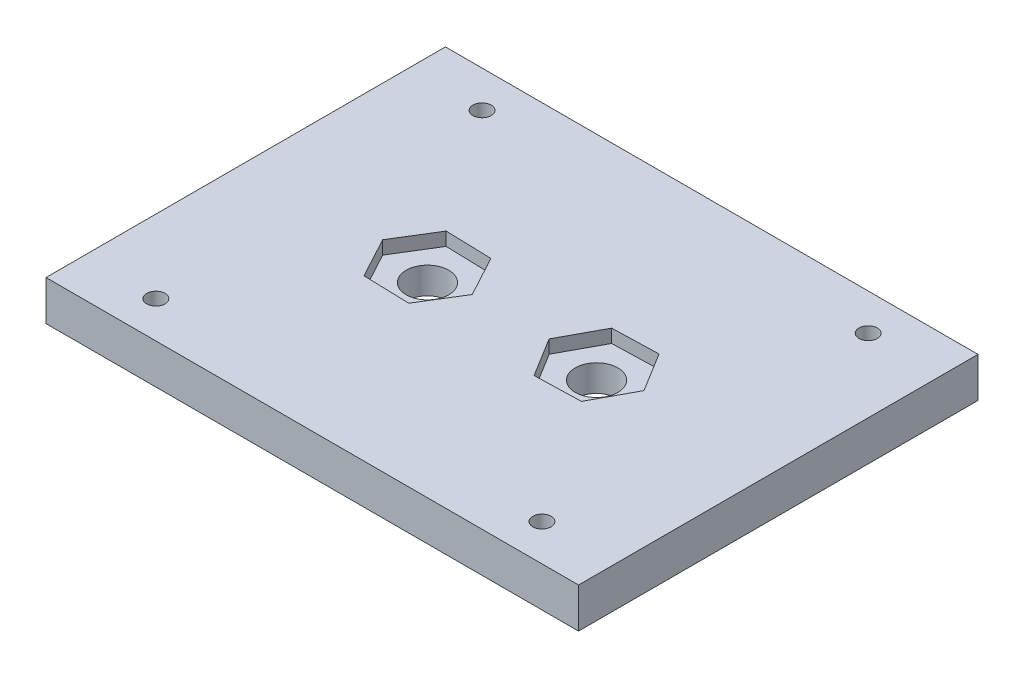
from build123d import *

# Parameters (mm, degrees)
SKETCH2_W               = 80
SKETCH2_H               = 60
BOSS_EXTRUDE2_DEPTH     = 6
SKETCH3_R               = 3.2
CUT_EXTRUDE1_DEPTH      = 6
CUT_EXTRUDE2_DEPTH      = 2
SKETCH6_R               = 1.375
CUT_EXTRUDE3_DEPTH      = 6
MIRROR4_COPY_1_SKETCH_R = 1.375
MIRROR4_COPY_1_DEPTH    = 6


with BuildPart() as part:
    # Sketch2 → Boss-Extrude2 (new body)
    with BuildSketch(Plane(origin=(0, 0, 0), x_dir=(1, 0, 0), z_dir=(0, 1, 0))):
        Rectangle(SKETCH2_W, SKETCH2_H)
    extrude(amount=BOSS_EXTRUDE2_DEPTH)

    # Sketch3 → Cut-Extrude1 (cut)
    with BuildSketch(Plane(origin=(0, 6, 0), x_dir=(1, 0, 0), z_dir=(0, 1, 0))):
        with Locations((-12.7, 0)):
            Circle(SKETCH3_R)
    cut_extrude1 = extrude(amount=-CUT_EXTRUDE1_DEPTH, mode=Mode.SUBTRACT)

    # Sketch5 → Cut-Extrude2 (cut)
    with BuildSketch(Plane(origin=(0, 6, 0), x_dir=(1, 0, 0), z_dir=(0, 1, 0))):
        Polygon((-9.409372911, -6.096865864), (-5.774645734, -0.198666278), (-9.065272823, 5.898199586), (-15.990627089, 6.096865864), (-19.625354266, 0.198666278), (-16.334727177, -5.898199586), align=None)
    cut_extrude2 = extrude(amount=-CUT_EXTRUDE2_DEPTH, mode=Mode.SUBTRACT)

    # Mirror2: Cut-Extrude1, Cut-Extrude2 across plane
    add(cut_extrude1.mirror(Plane(origin=(0, 0, 0), x_dir=(0, 0, 1), z_dir=(1, 0, 0))), mode=Mode.SUBTRACT)
    add(cut_extrude2.mirror(Plane(origin=(0, 0, 0), x_dir=(0, 0, 1), z_dir=(1, 0, 0))), mode=Mode.SUBTRACT)

    # Sketch6 → Cut-Extrude3 (cut)
    with BuildSketch(Plane(origin=(0, 6, 0), x_dir=(1, 0, 0), z_dir=(0, 1, 0))):
        with Locations((-29, 24.5)):
            Circle(SKETCH6_R)
    cut_extrude3 = extrude(amount=-CUT_EXTRUDE3_DEPTH, mode=Mode.SUBTRACT)

    # Mirror3: Cut-Extrude3 across plane
    add(cut_extrude3.mirror(Plane.XY), mode=Mode.SUBTRACT)

    # Mirror4: Cut-Extrude3 across plane
    add(cut_extrude3.mirror(Plane(origin=(0, 0, 0), x_dir=(0, 0, 1), z_dir=(1, 0, 0))), mode=Mode.SUBTRACT)

    # Mirror4 copy 1 sketch → Mirror4 copy 1 (cut)
    with BuildSketch(Plane(origin=(0, 6, 0), x_dir=(-1, 0, 0), z_dir=(0, 1, 0))):
        with Locations((-29, 24.5)):
            Circle(MIRROR4_COPY_1_SKETCH_R)
    extrude(amount=-MIRROR4_COPY_1_DEPTH, mode=Mode.SUBTRACT)


solid = part.part
